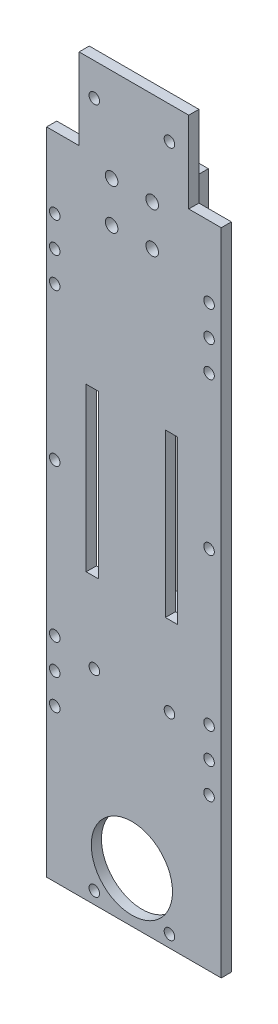
from build123d import *

# Parameters (mm, degrees)
SKETCH_1_R      = 1.3
SKETCH_1_R_2    = 10
SKETCH_1_W      = 3
SKETCH_1_H      = 40
SKETCH_1_R_3    = 1.55
EXTRUDE_1_DEPTH = 2.5
SKETCH_2_R      = 1.55
SKETCH_2_W      = 3
SKETCH_2_H      = 28.5
SKETCH_2_W_2    = 4
SKETCH_2_H_2    = 27.5
SKETCH_2_W_3    = 9.575
SKETCH_2_H_3    = 3.5
SKETCH_2_W_4    = 8.925
EXTRUDE_2_DEPTH = 6


with BuildPart() as part:
    # 草图1 → 凸台-拉伸1 (new body)
    with BuildSketch(Plane.XY):
        Polygon((22, -90), (22, 70), (14, 70), (14, 90), (-13, 90), (-13, 70), (-21, 70), (-21, -90), (-16, -90), (-2.5, -90), (2.5, -90), (16, -90), align=None)
        with Locations((-19, -52.5)):
            Circle(SKETCH_1_R, mode=Mode.SUBTRACT)
        with Locations((-9.25, -87)):
            Circle(SKETCH_1_R, mode=Mode.SUBTRACT)
        with Locations((0, -77.615961472)):
            Circle(SKETCH_1_R_2, mode=Mode.SUBTRACT)
        with Locations((-19, -45)):
            Circle(SKETCH_1_R, mode=Mode.SUBTRACT)
        with Locations((-19, -37.5)):
            Circle(SKETCH_1_R, mode=Mode.SUBTRACT)
        with Locations((-9.25, -39.714835276)):
            Circle(SKETCH_1_R, mode=Mode.SUBTRACT)
        with Locations((9.25, -87)):
            Circle(SKETCH_1_R, mode=Mode.SUBTRACT)
        with Locations((19, -52.5)):
            Circle(SKETCH_1_R, mode=Mode.SUBTRACT)
        with Locations((9.25, -39.714835276)):
            Circle(SKETCH_1_R, mode=Mode.SUBTRACT)
        with Locations((19, -45)):
            Circle(SKETCH_1_R, mode=Mode.SUBTRACT)
        with Locations((19, -37.5)):
            Circle(SKETCH_1_R, mode=Mode.SUBTRACT)
        with Locations((-19, 0)):
            Circle(SKETCH_1_R, mode=Mode.SUBTRACT)
        with Locations((-19, 37.5)):
            Circle(SKETCH_1_R, mode=Mode.SUBTRACT)
        with Locations((-9.75, 0)):
            Rectangle(SKETCH_1_W, SKETCH_1_H, mode=Mode.SUBTRACT)
        with Locations((-19, 45)):
            Circle(SKETCH_1_R, mode=Mode.SUBTRACT)
        with Locations((-19, 52.5)):
            Circle(SKETCH_1_R, mode=Mode.SUBTRACT)
        with Locations((-5, 57)):
            Circle(SKETCH_1_R_3, mode=Mode.SUBTRACT)
        with Locations((-5, 67)):
            Circle(SKETCH_1_R_3, mode=Mode.SUBTRACT)
        with Locations((-9.25, 82)):
            Circle(SKETCH_1_R, mode=Mode.SUBTRACT)
        with Locations((9.75, 0)):
            Rectangle(SKETCH_1_W, SKETCH_1_H, mode=Mode.SUBTRACT)
        with Locations((19, 0)):
            Circle(SKETCH_1_R, mode=Mode.SUBTRACT)
        with Locations((19, 37.5)):
            Circle(SKETCH_1_R, mode=Mode.SUBTRACT)
        with Locations((5, 57)):
            Circle(SKETCH_1_R_3, mode=Mode.SUBTRACT)
        with Locations((5, 67)):
            Circle(SKETCH_1_R_3, mode=Mode.SUBTRACT)
        with Locations((9.25, 82)):
            Circle(SKETCH_1_R, mode=Mode.SUBTRACT)
        with Locations((19, 45)):
            Circle(SKETCH_1_R, mode=Mode.SUBTRACT)
        with Locations((19, 52.5)):
            Circle(SKETCH_1_R, mode=Mode.SUBTRACT)
    extrude(amount=EXTRUDE_1_DEPTH)

    # 草图2 → 凸台-拉伸2 (add)
    with BuildSketch(Plane(origin=(0, 0, 0), x_dir=(-1, 0, 0), z_dir=(0, 0, -1))):
        Polygon((9.675, 72.5), (9.675, 52.5), (1.675, 52.5), (-0.325, 52.5), (-2.325, 52.5), (-10.325, 52.5), (-10.325, 72.5), align=None)
        with Locations((-5, 57)):
            Circle(SKETCH_2_R, mode=Mode.SUBTRACT)
        with Locations((5, 67)):
            Circle(SKETCH_2_R, mode=Mode.SUBTRACT)
        with Locations((-5, 67)):
            Circle(SKETCH_2_R, mode=Mode.SUBTRACT)
        with Locations((5, 57)):
            Circle(SKETCH_2_R, mode=Mode.SUBTRACT)
        with Locations((8.175, 38.25)):
            Rectangle(SKETCH_2_W, SKETCH_2_H)
        Polygon((-2.325, 20.5), (1.675, 20.5), (1.675, 24), (1.675, 32.5), (1.675, 52.5), (-0.325, 52.5), (-2.325, 52.5), (-2.325, 32.5), (-2.325, 24), align=None)
        with Locations((-8.825, 38.25)):
            Rectangle(SKETCH_2_W, SKETCH_2_H)
        Polygon((-12.325, 20.5), (-2.325, 20.5), (-2.325, 24), (-7.325, 24), (-10.325, 24), (-12.325, 24), align=None)
        Polygon((1.675, 24), (1.675, 20.5), (11.675, 20.5), (11.675, 24), (9.675, 24), (6.675, 24), align=None)
        Polygon((-2.325, 20), (-2.325, -21.5), (1.675, -21.5), (1.675, 20.5), (-2.325, 20.5), align=None)
        with Locations((-0.325, -38.75)):
            Rectangle(SKETCH_2_W_2, SKETCH_2_H_2)
        with Locations((6.4625, -23.25)):
            Rectangle(SKETCH_2_W_3, SKETCH_2_H_3)
        with Locations((-0.325, -23.25)):
            Rectangle(SKETCH_2_W_2, SKETCH_2_H_3)
        with Locations((-6.7875, -23.25)):
            Rectangle(SKETCH_2_W_4, SKETCH_2_H_3)
        Polygon((-11.25, -52.5), (-2.325, -52.5), (1.675, -52.5), (11.25, -52.5), (11.25, -56), (-11.25, -56), align=None)
    extrude(amount=EXTRUDE_2_DEPTH)


solid = part.part
